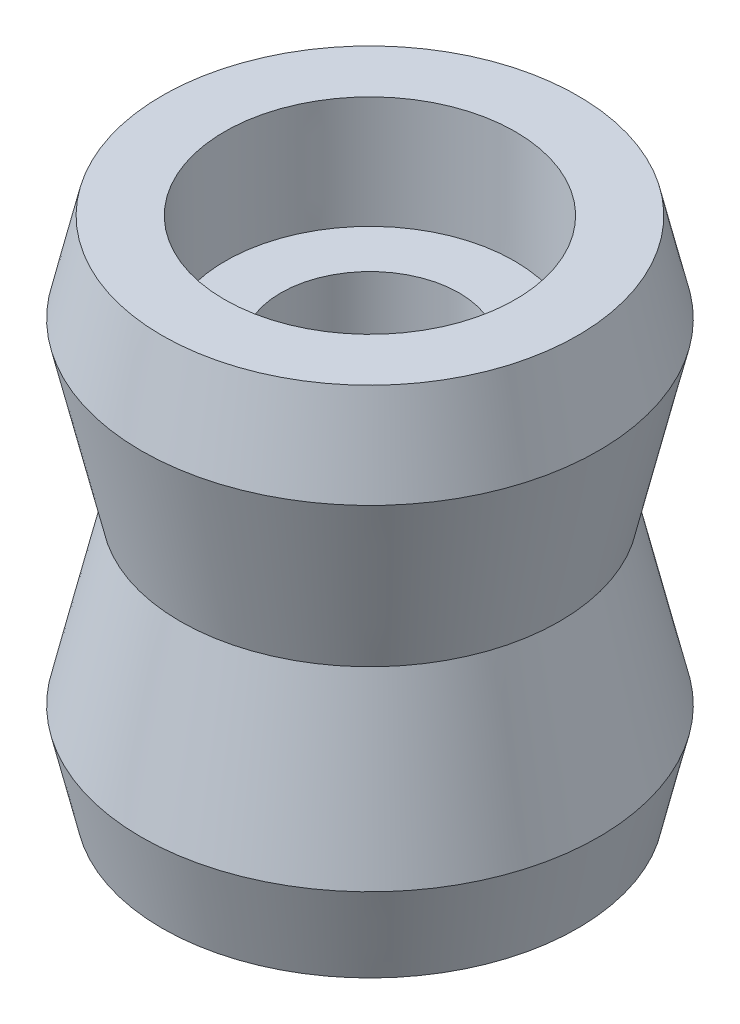
from build123d import *

# Parameters (mm, degrees)
SKETCH2_R           = 4
BOSS_EXTRUDE1_DEPTH = 0.2


with BuildPart() as part:
    # Sketch1 → Revolve1 (revolve)
    with BuildSketch(Plane.XY):
        Polygon((4, -3.313539221), (4, 9.698172784), (6.48, 9.698172784), (6.52, 14.698172784), (9.315596793, 14.698172784), (10.25, 10.692316782), (8.5, 3.192316782), (10.25, -4.307683218), (9.315596793, -8.313539221), (6.52, -8.313539221), (6.48, -3.313539221), align=None)
    revolve(axis=Axis((0, 42.323455848, 0), (0, -1, 0)))

    # Sketch2 → Boss-Extrude1 (add)
    with BuildSketch(Plane.XZ.offset(3.313539221)):
        Circle(SKETCH2_R)
    extrude(amount=-BOSS_EXTRUDE1_DEPTH)


solid = part.part
